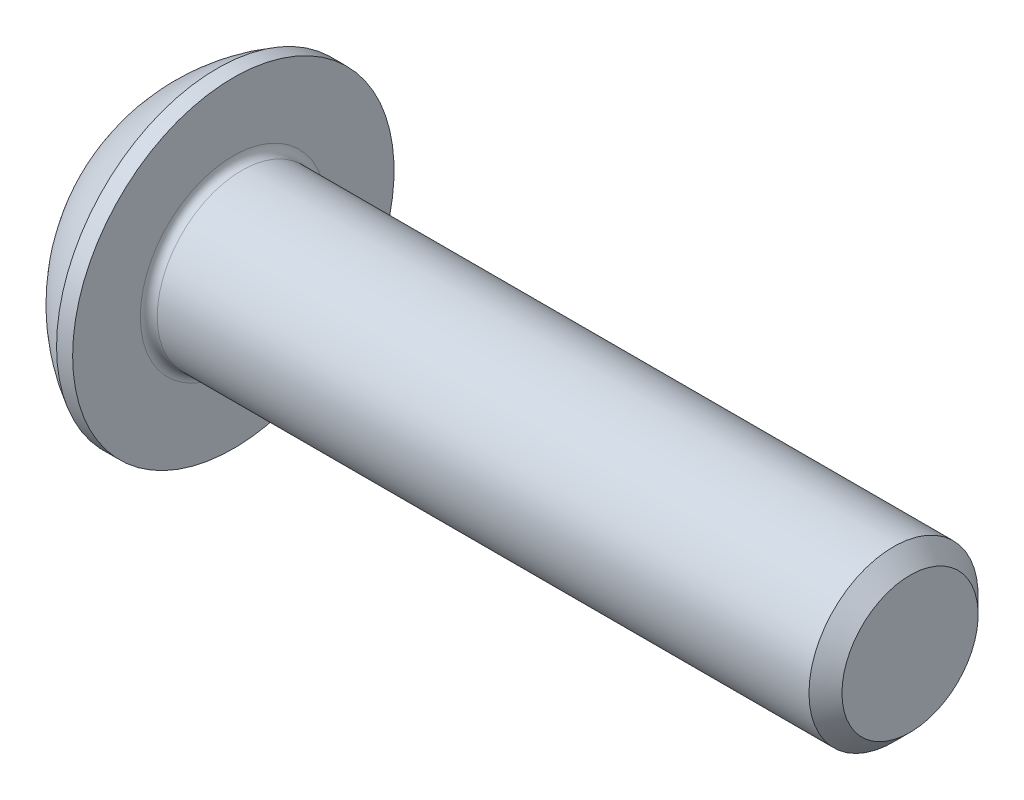
from build123d import *

# Parameters (mm, degrees)
FILLET1_R   = 0.2
HEX_2_DEPTH = 1.3


with BuildPart() as part:
    # BodySke → BaseBody (revolve)
    with BuildSketch(Plane.XY):
        with BuildLine():
            Line((18.2, 0), (18.2, 1.61))
            Line((18.2, 1.61), (17.81, 2))
            Line((17.81, 2), (2.2, 2))
            Line((2.2, 2), (2.2, 3.8))
            Line((2.2, 3.8), (1.82, 3.8))
            ThreePointArc((1.82, 3.8), (0.762013659, 2.991755338), (0, 1.9))
            Line((0, 1.9), (0, 0))
            Line((0, 0), (18.2, 0))
        make_face()
    revolve(axis=Axis((0, 0, 0), (1, 0, 0)))

    # Fillet1
    fillet1_edges = [part.edges().sort_by_distance(p)[0] for p in [
        (2.2, -2, 0),
    ]]
    fillet(fillet1_edges, radius=FILLET1_R)

    # Sketch2 → PreBroach (revolve, cut)
    with BuildSketch(Plane.XY):
        Polygon((0, 1.25), (1.3, 1.25), (2.021687836, 0), (0, 0), align=None)
    revolve(axis=Axis((0, 0, 0), (1, 0, 0)), mode=Mode.SUBTRACT)

    # Sketch3 → Hex 2 (cut)
    with BuildSketch(Plane(origin=(0, 0, 0), x_dir=(0, 0, -1), z_dir=(1, 0, 0))):
        Polygon((-1.25, -0.721687836), (-1.25, 0.721687836), (0, 1.443375673), (1.25, 0.721687836), (1.25, -0.721687836), (0, -1.443375673), align=None)
    extrude(amount=HEX_2_DEPTH, mode=Mode.SUBTRACT)


solid = part.part
